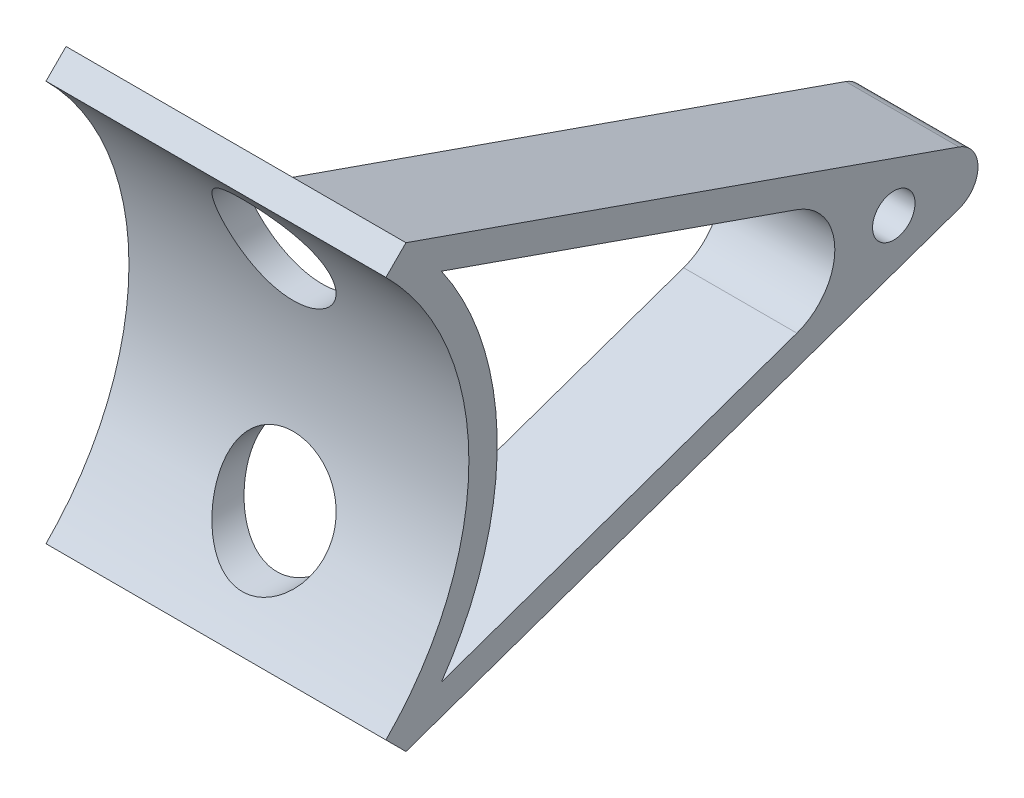
from build123d import *

# Parameters (mm, degrees)
BOSS_EXTRUDE1_DEPTH = 120
BOSS_EXTRUDE2_DEPTH = 40
SKETCH4_R           = 7.5
CUT_EXTRUDE1_DEPTH  = 40
SKETCH6_R           = 20
CUT_EXTRUDE2_DEPTH  = 280.73097144


with BuildPart() as part:
    # Sketch1 → Boss-Extrude1 (new body)
    with BuildSketch(Plane(origin=(0, 0, 0), x_dir=(0, 0, -1), z_dir=(1, 0, 0))):
        with BuildLine():
            Line((70.710678119, 70.710678119), (77.781745931, 77.781745931))
            ThreePointArc((77.781745931, 77.781745931), (110, 0), (77.781745931, -77.781745931))
            Line((77.781745931, -77.781745931), (70.710678119, -70.710678119))
            ThreePointArc((70.710678119, -70.710678119), (100, 0), (70.710678119, 70.710678119))
        make_face()
    extrude(amount=BOSS_EXTRUDE1_DEPTH)

    # Sketch2 → Boss-Extrude2 (add)
    with BuildSketch(Plane(origin=(120, 0, 0), x_dir=(0, 0, -1), z_dir=(1, 0, 0))):
        with BuildLine():
            Line((77.781745931, 77.781745931), (273.03467839, 9.438512616))
            ThreePointArc((273.03467839, 9.438512616), (279.73097144, 0), (273.03467839, -9.438512616))
            Line((273.03467839, -9.438512616), (77.781745931, -77.781745931))
            Line((77.781745931, -77.781745931), (77.781745931, -67.18685624))
            Line((77.781745931, -67.18685624), (215.80032822, -18.877025231))
            ThreePointArc((215.80032822, -18.877025231), (229.192914321, 0), (215.80032822, 18.877025231))
            Line((215.80032822, 18.877025231), (77.781745931, 67.18685624))
            Line((77.781745931, 67.18685624), (77.781745931, 77.781745931))
        make_face()
    extrude(amount=-BOSS_EXTRUDE2_DEPTH)

    # Sketch4 → Cut-Extrude1 (cut)
    with BuildSketch(Plane(origin=(120, 0, 0), x_dir=(0, 0, -1), z_dir=(1, 0, 0))):
        with Locations((250, 0)):
            Circle(SKETCH4_R)
    extrude(amount=-CUT_EXTRUDE1_DEPTH, mode=Mode.SUBTRACT)

    # Sketch6 → Cut-Extrude2 (cut, through all)
    with BuildSketch(Plane.XY):
        with Locations((60, 40)):
            Circle(SKETCH6_R)
        with Locations((60, -40)):
            Circle(SKETCH6_R)
    extrude(amount=-CUT_EXTRUDE2_DEPTH, mode=Mode.SUBTRACT)


solid = part.part
